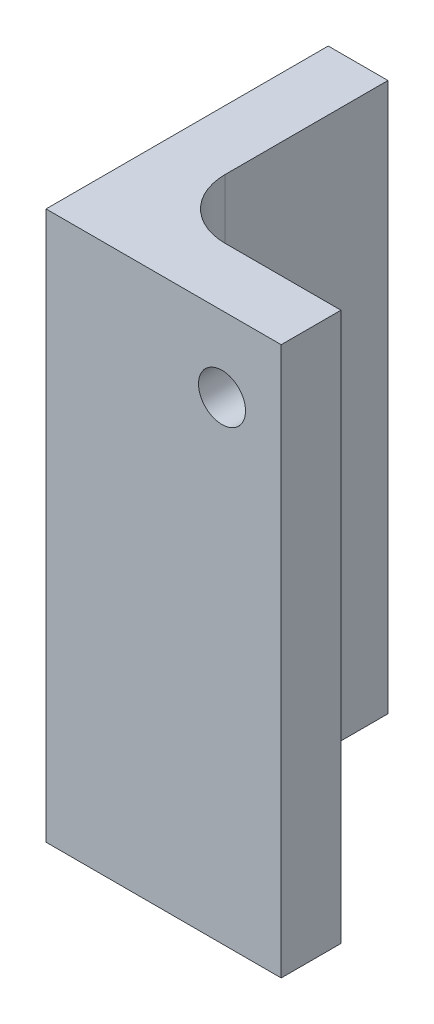
from build123d import *

# Parameters (mm, degrees)
BOSS_EXTRUDE1_DEPTH = 58.31
SKETCH3_R           = 2.5
CUT_EXTRUDE1_DEPTH  = 7.35
SKETCH4_R           = 2.5
CUT_EXTRUDE2_DEPTH  = 7.35
SKETCH5_W           = 25
SKETCH5_H           = 30
CUT_EXTRUDE3_DEPTH  = 59.31


with BuildPart() as part:
    # Sketch2 → Boss-Extrude1 (new body)
    with BuildSketch(Plane(origin=(0, 0, 0), x_dir=(1, 0, 0), z_dir=(0, 1, 0))):
        with BuildLine():
            Line((0, 0), (0, 30))
            Line((0, 30), (25, 30))
            Line((25, 30), (25, 23.65))
            Line((25, 23.65), (12.7, 23.65))
            ThreePointArc((12.7, 23.65), (8.209871939, 21.790128061), (6.35, 17.3))
            Line((6.35, 17.3), (6.35, 0))
            Line((6.35, 0), (0, 0))
        make_face()
    boss_extrude1 = extrude(amount=BOSS_EXTRUDE1_DEPTH)

    # Sketch3 → Cut-Extrude1 (cut, through all)
    with BuildSketch(Plane(origin=(6.35, 0, 0), x_dir=(0, 0, -1), z_dir=(1, 0, 0))):
        with Locations((8.65, 10)):
            Circle(SKETCH3_R)
        with Locations((8.65, 30)):
            Circle(SKETCH3_R)
    cut_extrude1 = extrude(amount=-CUT_EXTRUDE1_DEPTH, mode=Mode.SUBTRACT)

    # Sketch4 → Cut-Extrude2 (cut, through all)
    with BuildSketch(Plane.XY.offset(-23.65)):
        with Locations((18.706720962, 50.31)):
            Circle(SKETCH4_R)
    cut_extrude2 = extrude(amount=-CUT_EXTRUDE2_DEPTH, mode=Mode.SUBTRACT)

    # Mirror1: Boss-Extrude1, Cut-Extrude1, Cut-Extrude2 across plane
    add(boss_extrude1.mirror(Plane(origin=(0, 58.31, 0), x_dir=(1, 0, 0), z_dir=(0, 0, -1))))
    add(cut_extrude1.mirror(Plane(origin=(0, 58.31, 0), x_dir=(1, 0, 0), z_dir=(0, 0, -1))), mode=Mode.SUBTRACT)
    add(cut_extrude2.mirror(Plane(origin=(0, 58.31, 0), x_dir=(1, 0, 0), z_dir=(0, 0, -1))), mode=Mode.SUBTRACT)

    # Sketch5 → Cut-Extrude3 (cut, through all)
    with BuildSketch(Plane(origin=(0, 58.31, 0), x_dir=(1, 0, 0), z_dir=(0, 1, 0))):
        with Locations((12.5, 15)):
            Rectangle(SKETCH5_W, SKETCH5_H)
    extrude(amount=-CUT_EXTRUDE3_DEPTH, mode=Mode.SUBTRACT)


solid = part.part
